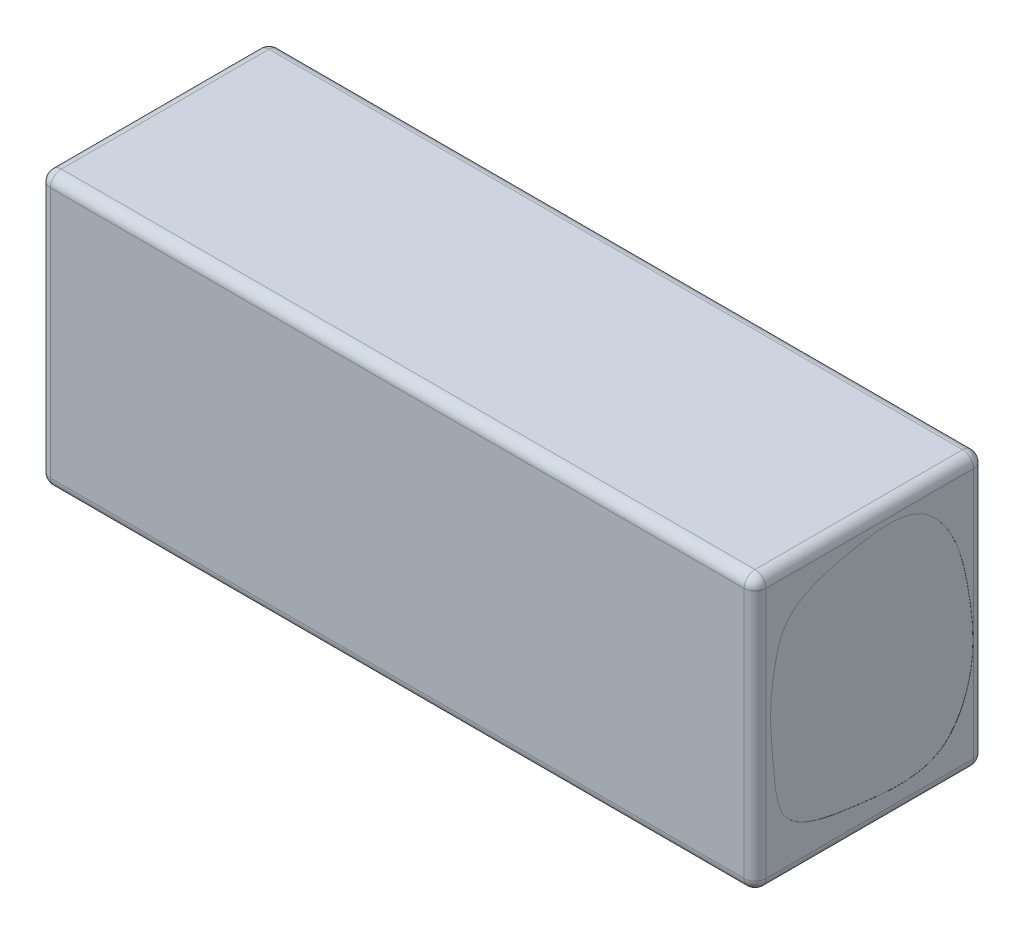
from build123d import *

# Parameters (mm, degrees)
CROQUIS2_W              = 131
CROQUIS2_H              = 42
SALIENTE_EXTRUIR1_DEPTH = 50
CORTAR_EXTRUIR1_DEPTH   = 0.02
REDONDEO1_R             = 2
CORTAR_EXTRUIR2_DEPTH   = 2


with BuildPart() as part:
    # Croquis2 → Saliente-Extruir1 (new body)
    with BuildSketch(Plane(origin=(0, 0, 0), x_dir=(1, 0, 0), z_dir=(0, 1, 0))):
        Rectangle(CROQUIS2_W, CROQUIS2_H)
    extrude(amount=SALIENTE_EXTRUIR1_DEPTH)

    # Croquis3 → Cortar-Extruir1 (cut)
    with BuildSketch(Plane(origin=(65.5, 0, 0), x_dir=(0, 0, -1), z_dir=(1, 0, 0))):
        with BuildLine():
            add(Edge.make_bspline(
                [(-17.112114557, 36.006296002), (-16.769875687, 37.42301657), (-15.057082788, 43.088866065), (-3.859638422, 46.362485269), (8.679768808, 48.154839826), (16.162022742, 38.858188467), (18.505026308, 27.939639658), (19.779716297, 16.168451708), (13.261180985, 3.841515951), (3.038463882, 4.622376827), (-6.441014061, 5.799969078), (-16.666974229, 7.476700806), (-17.543271482, 18.80297348), (-18.518864255, 27.195655921), (-17.793454872, 33.185842442), (-17.112114557, 36.006296002)],
                knots=[0, 0, 0, 0, 0.032914091, 0.131790069, 0.239123046, 0.300139284, 0.384993454, 0.497153717, 0.570211354, 0.671370628, 0.697843576, 0.799265567, 0.861163185, 0.934473554, 1, 1, 1, 1], degree=3))
        make_face()
    extrude(amount=-CORTAR_EXTRUIR1_DEPTH, mode=Mode.SUBTRACT)

    # Redondeo1
    redondeo1_edges = [part.edges().sort_by_distance(p)[0] for p in [
        (-65.5, 50, 0),
        (0, 50, 21),
        (65.5, 50, 0),
        (0, 0, 21),
        (-65.5, 0, 0),
        (0, 0, -21),
        (65.5, 0, 0),
        (0, 50, -21),
        (65.5, 25, 21),
        (-65.5, 25, 21),
        (-65.5, 25, -21),
        (65.5, 25, -21),
    ]]
    fillet(redondeo1_edges, radius=REDONDEO1_R)

    # Croquis4 → Cortar-Extruir2 (cut)
    with BuildSketch(Plane.ZY.offset(65.5)):
        with BuildLine():
            add(Edge.make_bspline(
                [(8.978661577, 42.558783476), (5.375949454, 43.867570791), (-1.149836325, 41.739656252), (-9.762030871, 44.554797073), (-16.510781784, 37.672215383), (-13.639271555, 25.861697119), (-23.105390544, 3.346347644), (-6.65065098, 8.75557637), (2.285497568, 3.421967675), (9.798682665, 8.179200373), (16.633242319, 13.22394434), (14.828389321, 19.837598078), (15.335298358, 26.153672342), (13.358929545, 31.415036468), (15.235898272, 38.524529705), (11.052519969, 41.805395623), (8.978661577, 42.558783476)],
                knots=[0, 0, 0, 0, 0.09132038, 0.159387605, 0.195313945, 0.300499967, 0.464636293, 0.542295544, 0.617262826, 0.702219659, 0.735857869, 0.814488947, 0.839285493, 0.891602027, 0.947432509, 1, 1, 1, 1], degree=3))
        make_face()
    extrude(amount=-CORTAR_EXTRUIR2_DEPTH, mode=Mode.SUBTRACT)


solid = part.part
